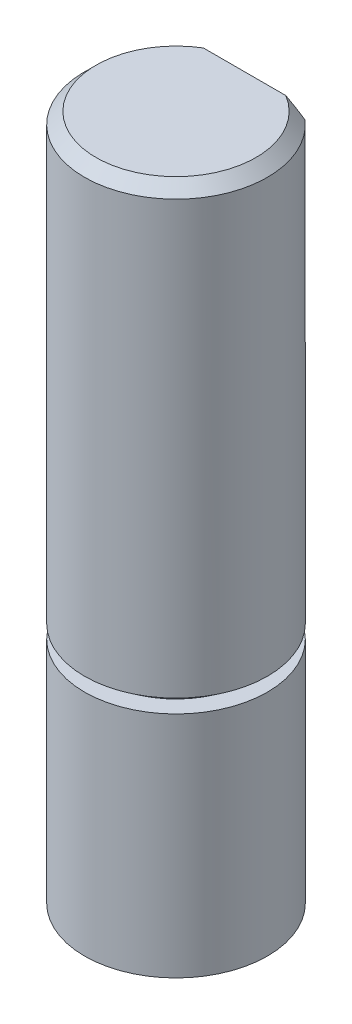
from build123d import *

# Parameters (mm, degrees)
SKETCH1_R                = 4
BOSS_EXTRUDE1_DEPTH      = 20
BOSS_EXTRUDE1_DEPTH_BACK = 10
CHAMFER1_SIZE            = 0.5
CUT_EXTRUDE1_DEPTH       = 12
SKETCH3_W                = 1.701892275
SKETCH3_H                = 0.6


with BuildPart() as part:
    # Sketch1 → Boss-Extrude1 (new body, two sides)
    with BuildSketch(Plane(origin=(0, 0, 0), x_dir=(1, 0, 0), z_dir=(0, 1, 0))) as boss_extrude1_sk:
        Circle(SKETCH1_R)
    extrude(amount=BOSS_EXTRUDE1_DEPTH)
    extrude(boss_extrude1_sk.sketch, amount=-BOSS_EXTRUDE1_DEPTH_BACK)

    # Chamfer1
    chamfer1_edges = [part.edges().sort_by_distance(p)[0] for p in [
        (-4, 20, 0),
    ]]
    chamfer(chamfer1_edges, length=CHAMFER1_SIZE)

    # Sketch2 → Cut-Extrude1 (cut)
    with BuildSketch(Plane(origin=(0, 20, 0), x_dir=(1, 0, 0), z_dir=(0, 1, 0))):
        with BuildLine():
            Line((-2.645751311, 3), (2.645751311, 3))
            ThreePointArc((2.645751311, 3), (0, 4), (-2.645751311, 3))
        make_face()
    extrude(amount=-CUT_EXTRUDE1_DEPTH, mode=Mode.SUBTRACT)

    # Sketch3 → Cut-Revolve1 (revolve, cut)
    with BuildSketch(Plane(origin=(0, 0, 0), x_dir=(0, 0, -1), z_dir=(1, 0, 0))):
        with Locations((4.050946138, 0.3)):
            Rectangle(SKETCH3_W, SKETCH3_H)
    revolve(axis=Axis((0, 0, 0), (0, 1, 0)), mode=Mode.SUBTRACT)


solid = part.part
